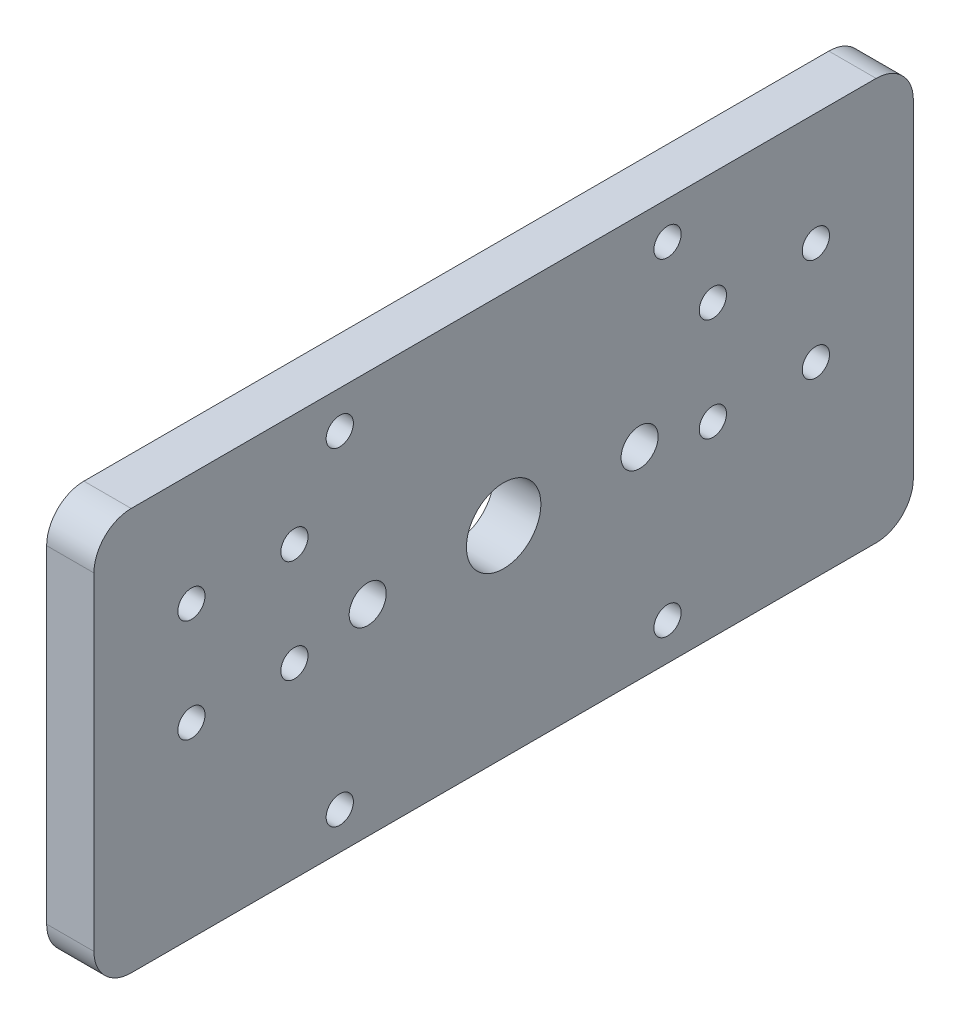
from build123d import *

# Parameters (mm, degrees)
SKETCH1_W              = 110
SKETCH1_H              = 54
BOSS_EXTRUDE1_DEPTH    = 6.35
FILLET1_R              = 5
F_6_CLEARANCE_HOLE1_D  = 3.6576
SKETCH5_R              = 5
CUT_EXTRUDE1_DEPTH     = 7.35
F_6_CLEARANCE_HOLE2_D  = 3.6576
F_10_CLEARANCE_HOLE1_D = 4.9784


with BuildPart() as part:
    # Sketch1 → Boss-Extrude1 (new body)
    with BuildSketch(Plane(origin=(0, 0, 0), x_dir=(0, 0, -1), z_dir=(1, 0, 0))):
        Rectangle(SKETCH1_W, SKETCH1_H)
    extrude(amount=BOSS_EXTRUDE1_DEPTH)

    # Fillet1
    fillet1_edges = [part.edges().sort_by_distance(p)[0] for p in [
        (3.175, -27, -55),
        (3.175, -27, 55),
        (3.175, 27, 55),
        (3.175, 27, -55),
    ]]
    fillet(fillet1_edges, radius=FILLET1_R)

    # #6 Clearance Hole1 (through all)
    with Locations(Plane(origin=(6.35, 0, 0), x_dir=(0, 0, -1), z_dir=(1, 0, 0))):
        with Locations((-22, 22), (22, 22), (22, -22), (-22, -22)):
            Hole(F_6_CLEARANCE_HOLE1_D / 2)

    # Sketch5 → Cut-Extrude1 (cut, through all)
    with BuildSketch(Plane(origin=(6.35, 0, 0), x_dir=(0, 0, -1), z_dir=(1, 0, 0))):
        Circle(SKETCH5_R)
    extrude(amount=-CUT_EXTRUDE1_DEPTH, mode=Mode.SUBTRACT)

    # #6 Clearance Hole2 (through all)
    with Locations(Plane(origin=(6.35, 0, 0), x_dir=(0, 0, -1), z_dir=(1, 0, 0))):
        with Locations((-41.914797213, 11.884797213), (-28.085202787, 11.884797213), (-28.085202787, -1.944797213), (-41.914797213, -1.944797213), (28.085202787, 11.884797213), (28.085202787, -1.944797213), (41.914797213, -1.944797213), (41.914797213, 11.884797213)):
            Hole(F_6_CLEARANCE_HOLE2_D / 2)

    # #10 Clearance Hole1 (through all)
    with Locations(Plane.ZY):
        with Locations((18.25, 0), (-18.25, 0)):
            Hole(F_10_CLEARANCE_HOLE1_D / 2)


solid = part.part
